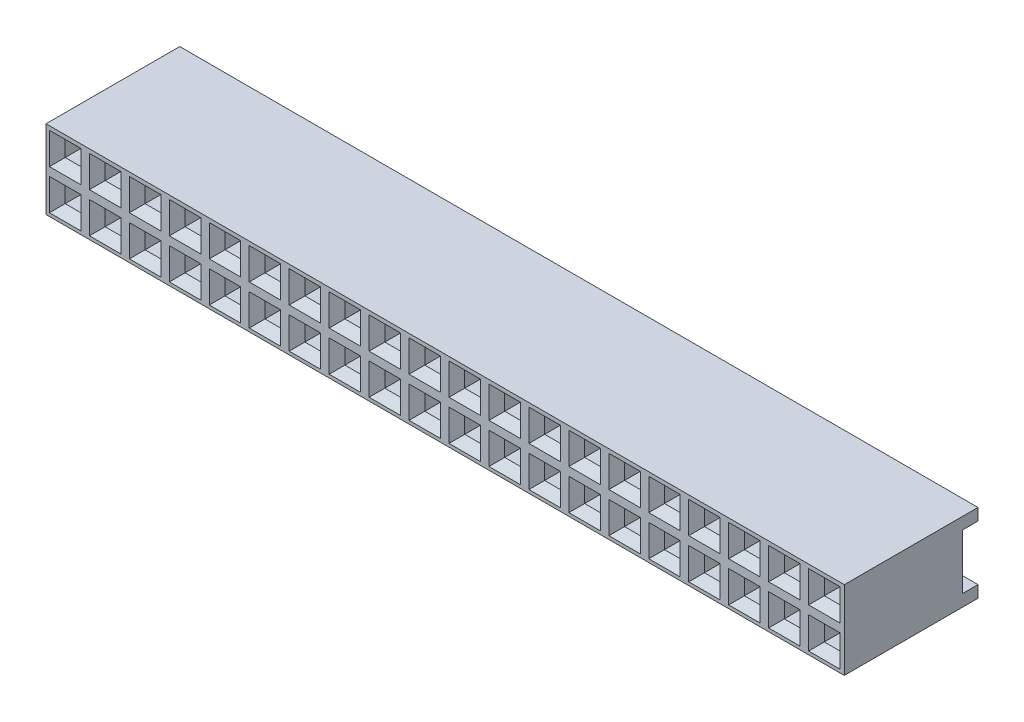
from build123d import *

# Parameters (mm, degrees)
BOSS_EXTRUDE1_DEPTH  = 50.75
SKETCH2_W            = 2
SKETCH2_H            = 0.6
CUT_EXTRUDE1_DEPTH   = 5.5
SKETCH3_W            = 1
SKETCH3_H            = 1
CUT_EXTRUDE2_DEPTH   = 6
SKETCH4_W            = 2
SKETCH4_H            = 2
CUT_EXTRUDE3_DEPTH   = 0.5
CUT_EXTRUDE3_TAPER   = 45
LPATTERN1_COUNT      = 20
LPATTERN1_PITCH      = 2.54
LPATTERN1_COUNT_DIR2 = 2
LPATTERN1_PITCH_DIR2 = 2.54


with BuildPart() as part:
    # Sketch1 → Boss-Extrude1 (new body)
    with BuildSketch(Plane(origin=(0, 0, 0), x_dir=(0, 0, -1), z_dir=(1, 0, 0))):
        Polygon((8.5, 5), (0, 5), (0, 0), (8.5, 0), (8.5, 0.75), (7.5, 0.75), (7.5, 4.25), (8.5, 4.25), align=None)
    extrude(amount=-BOSS_EXTRUDE1_DEPTH)

    # Sketch2 → Cut-Extrude1 (cut)
    with BuildSketch(Plane(origin=(0, 0, -7.5), x_dir=(-1, 0, 0), z_dir=(0, 0, -1))):
        with Locations((1.27, 3.95)):
            Rectangle(SKETCH2_W, SKETCH2_H)
    cut_extrude1 = extrude(amount=-CUT_EXTRUDE1_DEPTH, mode=Mode.SUBTRACT)

    # Sketch3 → Cut-Extrude2 (cut)
    with BuildSketch(Plane(origin=(0, 0, 0), x_dir=(-1, 0, 0), z_dir=(0, 0, -1))):
        with Locations((1.27, 3.75)):
            Rectangle(SKETCH3_W, SKETCH3_H)
    cut_extrude2 = extrude(amount=CUT_EXTRUDE2_DEPTH, mode=Mode.SUBTRACT)

    # Sketch4 → Cut-Extrude3 (cut)
    with BuildSketch(Plane.XY):
        with Locations((-1.27, 3.75)):
            Rectangle(SKETCH4_W, SKETCH4_H)
    cut_extrude3 = extrude(amount=-CUT_EXTRUDE3_DEPTH, taper=CUT_EXTRUDE3_TAPER, mode=Mode.SUBTRACT)

    # LPattern1: Cut-Extrude1, Cut-Extrude2, Cut-Extrude3 20 × 2
    with Locations(*[(-i * LPATTERN1_PITCH, -j * LPATTERN1_PITCH_DIR2, 0) for i in range(LPATTERN1_COUNT) for j in range(LPATTERN1_COUNT_DIR2) if (i, j) != (0, 0)]):
        add(cut_extrude1, mode=Mode.SUBTRACT)
        add(cut_extrude2, mode=Mode.SUBTRACT)
        add(cut_extrude3, mode=Mode.SUBTRACT)


solid = part.part
